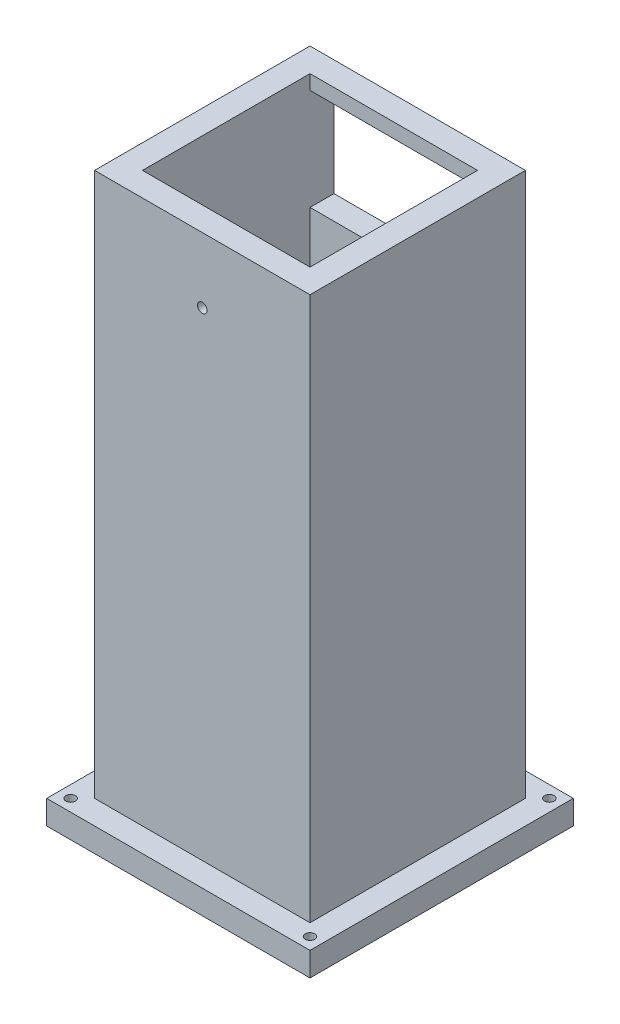
from build123d import *

# Parameters (mm, degrees)
CROQUIS1_W                 = 45
CROQUIS1_H                 = 45
SALIENTE_EXTRUIR1_DEPTH    = 300
CROQUIS4_W                 = 18
CROQUIS4_H                 = 34
CORTAR_EXTRUIR2_DEPTH      = 46
CROQUIS8_W                 = 35
CROQUIS8_H                 = 35
CORTAR_EXTRUIR3_DEPTH      = 301
CROQUIS9_W                 = 35
CROQUIS9_H                 = 21.174410022
CORTAR_EXTRUIR4_DEPTH      = 10
CROQUIS10_R                = 1
CORTAR_EXTRUIR5_DEPTH      = 10
CROQUIS11_W                = 45
CROQUIS11_H                = 26.387879272
CORTAR_EXTRUIR6_DEPTH      = 46
CROQUIS13_W                = 45
CROQUIS13_H                = 160
CORTAR_EXTRUIR7_DEPTH      = 23.5
CORTAR_EXTRUIR7_DEPTH_BACK = 23.5
CROQUIS14_W                = 55
CROQUIS14_H                = 55
SALIENTE_EXTRUIR2_DEPTH    = 5
CROQUIS16_R                = 1
CORTAR_EXTRUIR8_DEPTH      = 1
CORTAR_EXTRUIR8_DEPTH_BACK = 119.612120728


with BuildPart() as part:
    # Croquis1 → Saliente-Extruir1 (new body)
    with BuildSketch(Plane(origin=(0, 0, 0), x_dir=(1, 0, 0), z_dir=(0, 1, 0))):
        Rectangle(CROQUIS1_W, CROQUIS1_H)
    extrude(amount=SALIENTE_EXTRUIR1_DEPTH)

    # Croquis4 → Cortar-Extruir2 (cut, through all)
    with BuildSketch(Plane.ZY.offset(22.5)):
        with Locations((13.5, 17)):
            Rectangle(CROQUIS4_W, CROQUIS4_H)
    extrude(amount=-CORTAR_EXTRUIR2_DEPTH, mode=Mode.SUBTRACT)

    # Croquis8 → Cortar-Extruir3 (cut, through all)
    with BuildSketch(Plane(origin=(0, 300, 0), x_dir=(1, 0, 0), z_dir=(0, 1, 0))):
        Rectangle(CROQUIS8_W, CROQUIS8_H)
    extrude(amount=-CORTAR_EXTRUIR3_DEPTH, mode=Mode.SUBTRACT)

    # Croquis9 → Cortar-Extruir4 (cut)
    with BuildSketch(Plane(origin=(0, 0, -22.5), x_dir=(-1, 0, 0), z_dir=(0, 0, -1))):
        with Locations((0, 260)):
            Rectangle(CROQUIS9_W, CROQUIS9_H)
    extrude(amount=-CORTAR_EXTRUIR4_DEPTH, mode=Mode.SUBTRACT)

    # Croquis10 → Cortar-Extruir5 (cut)
    with BuildSketch(Plane.XY.offset(22.5)):
        with Locations((0, 260)):
            Circle(CROQUIS10_R)
    extrude(amount=-CORTAR_EXTRUIR5_DEPTH, mode=Mode.SUBTRACT)

    # Croquis11 → Cortar-Extruir6 (cut, through all)
    with BuildSketch(Plane.XY.offset(22.5)):
        with Locations((0, 286.806060364)):
            Rectangle(CROQUIS11_W, CROQUIS11_H)
    extrude(amount=-CORTAR_EXTRUIR6_DEPTH, mode=Mode.SUBTRACT)

    # Croquis13 → Cortar-Extruir7 (cut, two sides)
    with BuildSketch(Plane(origin=(0, 0, 0), x_dir=(0, 0, -1), z_dir=(1, 0, 0))) as cortar_extruir7_sk:
        with Locations((0, 80)):
            Rectangle(CROQUIS13_W, CROQUIS13_H)
    extrude(amount=CORTAR_EXTRUIR7_DEPTH, mode=Mode.SUBTRACT)
    extrude(cortar_extruir7_sk.sketch, amount=-CORTAR_EXTRUIR7_DEPTH_BACK, mode=Mode.SUBTRACT)

    # Croquis14 → Saliente-Extruir2 (add)
    with BuildSketch(Plane.XZ.offset(-160)):
        Rectangle(CROQUIS14_W, CROQUIS14_H)
    extrude(amount=SALIENTE_EXTRUIR2_DEPTH)

    # Croquis16 → Cortar-Extruir8 (cut, two sides)
    with BuildSketch(Plane.XZ.offset(-155)) as cortar_extruir8_sk:
        with Locations((25, 25)):
            Circle(CROQUIS16_R)
        with Locations((-25, 25)):
            Circle(CROQUIS16_R)
        with Locations((-25, -25)):
            Circle(CROQUIS16_R)
        with Locations((25, -25)):
            Circle(CROQUIS16_R)
    extrude(amount=CORTAR_EXTRUIR8_DEPTH, mode=Mode.SUBTRACT)
    extrude(cortar_extruir8_sk.sketch, amount=-CORTAR_EXTRUIR8_DEPTH_BACK, mode=Mode.SUBTRACT)


solid = part.part
